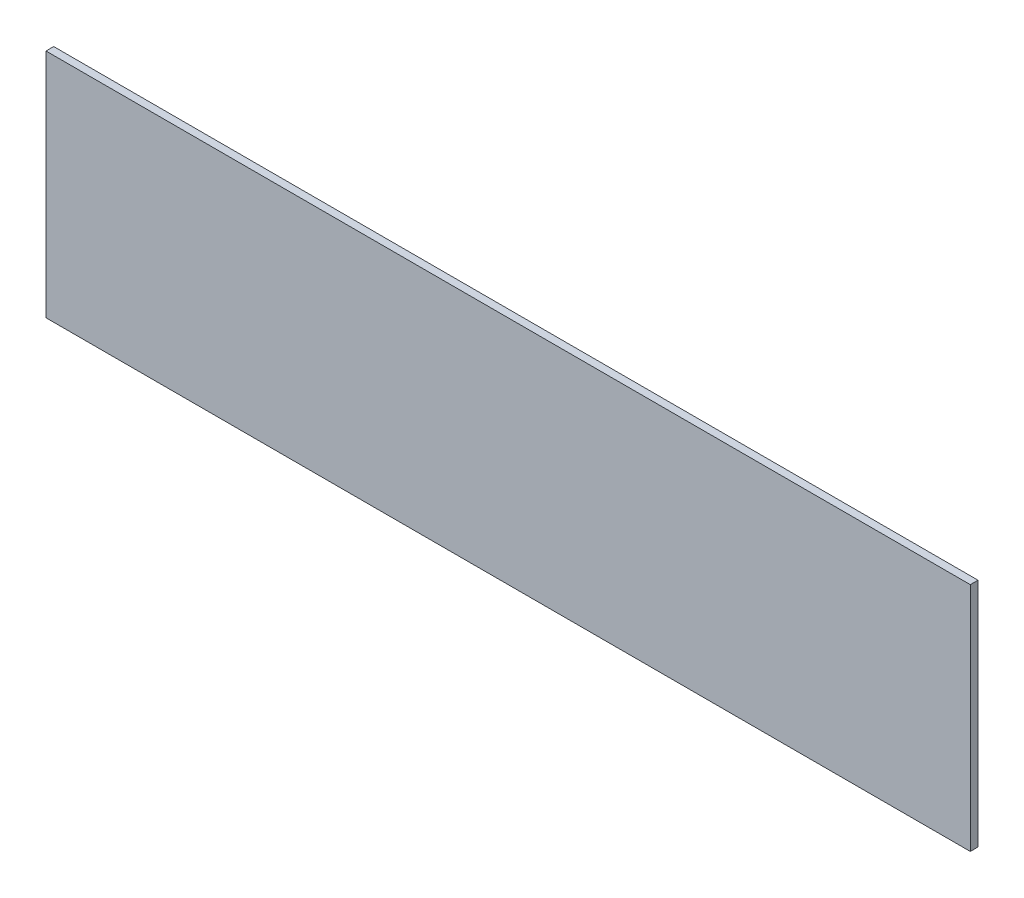
from build123d import *

# Parameters (mm, degrees)
SKETCH1_W           = 304.8
SKETCH1_H           = 76.2
BOSS_EXTRUDE1_DEPTH = 2.54


with BuildPart() as part:
    # Sketch1 → Boss-Extrude1 (new body)
    with BuildSketch(Plane.XY):
        Rectangle(SKETCH1_W, SKETCH1_H)
    extrude(amount=BOSS_EXTRUDE1_DEPTH)


solid = part.part
